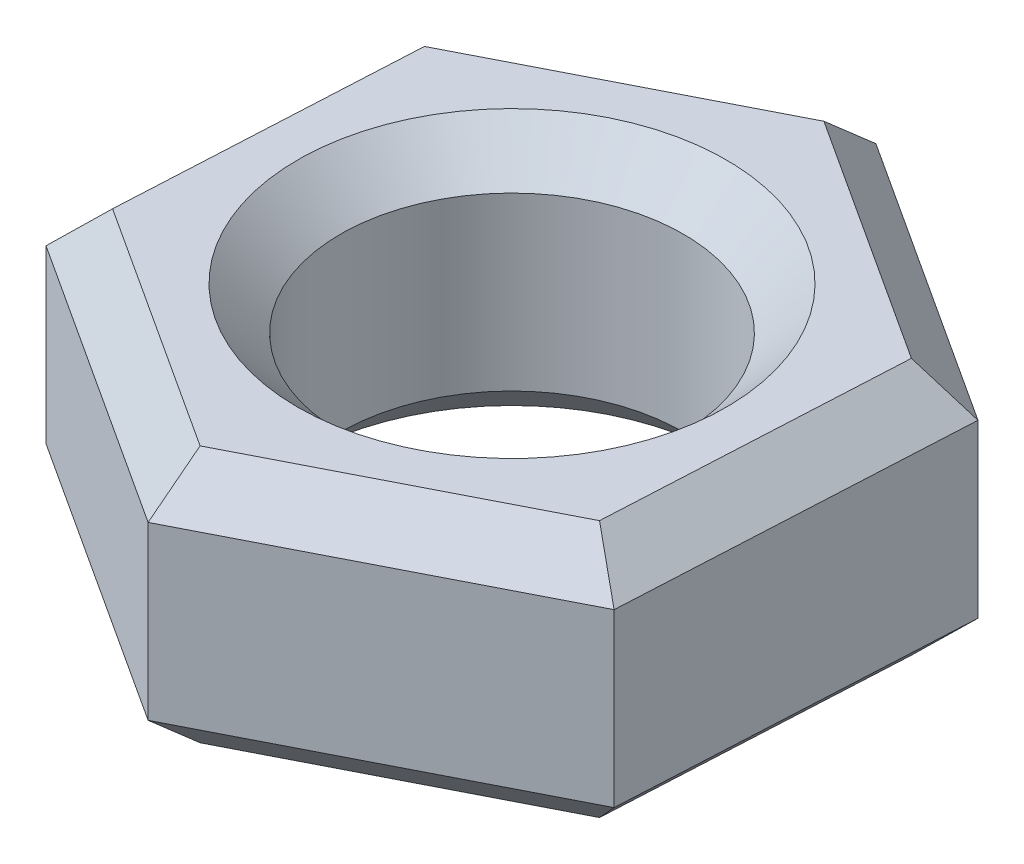
from build123d import *

# Parameters (mm, degrees)
SKETCH1_R           = 4
BOSS_EXTRUDE1_DEPTH = 6
CHAMFER1_SIZE       = 1


with BuildPart() as part:
    # Sketch1 → Boss-Extrude1 (new body)
    with BuildSketch(Plane(origin=(0, 0, 0), x_dir=(1, 0, 0), z_dir=(0, 1, 0))):
        Polygon((6.781243349, -4.398644334), (7.19995941, 3.673406842), (0.418716061, 8.072051176), (-6.781243349, 4.398644334), (-7.19995941, -3.673406842), (-0.418716061, -8.072051176), align=None)
        with Locations(Location((0, 0, 0), (0, 0, 270))):  # turned: the seam where the file's is
            Circle(SKETCH1_R, mode=Mode.SUBTRACT)
    extrude(amount=BOSS_EXTRUDE1_DEPTH)

    # Chamfer1
    chamfer1_edges = [part.edges().sort_by_distance(p)[0] for p in [
        (3.809337736, 6, -5.872729009),
        (-3.181263644, 6, -6.235347755),
        (-6.990601379, 6, -0.362618746),
        (0, 0, -4),
        (0, 6, -4),
        (-3.809337736, 6, 5.872729009),
        (3.181263644, 6, 6.235347755),
        (-3.809337736, 0, 5.872729009),
        (-6.990601379, 0, -0.362618746),
        (-3.181263644, 0, -6.235347755),
        (6.990601379, 6, 0.362618746),
        (3.809337736, 0, -5.872729009),
        (6.990601379, 0, 0.362618746),
        (3.181263644, 0, 6.235347755),
    ]]
    chamfer(chamfer1_edges, length=CHAMFER1_SIZE)


solid = part.part
